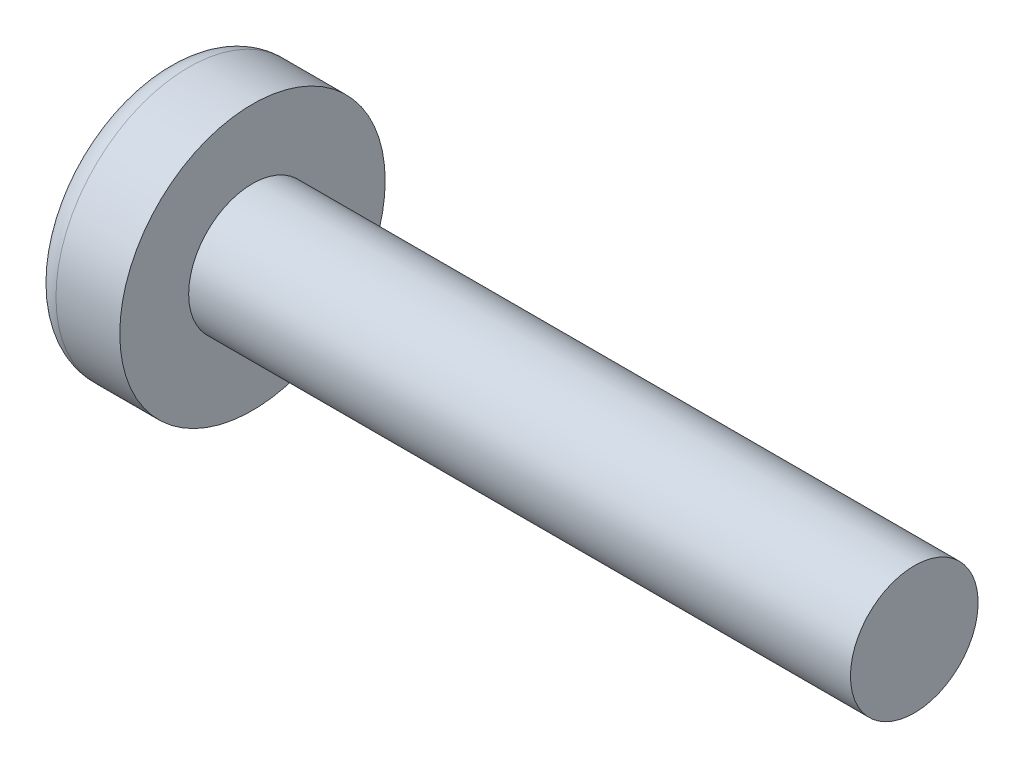
from build123d import *

# Parameters (mm, degrees)
SKETCH3_W         = 0.74
SKETCH3_H         = 2.9
SKETCH4_W         = 0.37
SKETCH4_H         = 0.37
CIRPATTERN1_COUNT = 2
CIRPATTERN1_ANGLE = 90


with BuildPart() as part:
    # BodySke → Base-Revolve (revolve)
    with BuildSketch(Plane.XY):
        with BuildLine():
            Line((1.6, 0.95), (1.6, 1.975))
            Line((1.6, 1.975), (0.650129312, 1.975))
            ThreePointArc((0.650129312, 1.975), (0.44459175, 1.910557626), (0.312639345, 1.740301724))
            ThreePointArc((0.312639345, 1.740301724), (0.078780473, 0.884080518), (0, 0))
            Line((0, 0), (11.45, 0))
            Line((11.45, 0), (11.45, 0.95))
            Line((11.45, 0.95), (1.6, 0.95))
        make_face()
    revolve(axis=Axis((-25.4, 0, 0), (1, 0, 0)))

    # Sketch3 → Cut-Loft1 section 0
    with BuildSketch(Plane(origin=(0, 0, 0), x_dir=(0, 0, -1), z_dir=(1, 0, 0))):
        Rectangle(SKETCH3_W, SKETCH3_H)
    # Sketch4 → Cut-Loft1 section 1
    with BuildSketch(Plane(origin=(1.76, 0, 0), x_dir=(0, 0, -1), z_dir=(1, 0, 0))):
        Rectangle(SKETCH4_W, SKETCH4_H)
    cut_loft1 = loft(mode=Mode.SUBTRACT)

    # CirPattern1: Cut-Loft1 ×2 about axis
    cirpattern1_axis = Axis((0, 0, 0), (1, 0, 0))
    for i in range(1, CIRPATTERN1_COUNT):
        add(cut_loft1.rotate(cirpattern1_axis, i * CIRPATTERN1_ANGLE / (CIRPATTERN1_COUNT - 1)), mode=Mode.SUBTRACT)


solid = part.part
